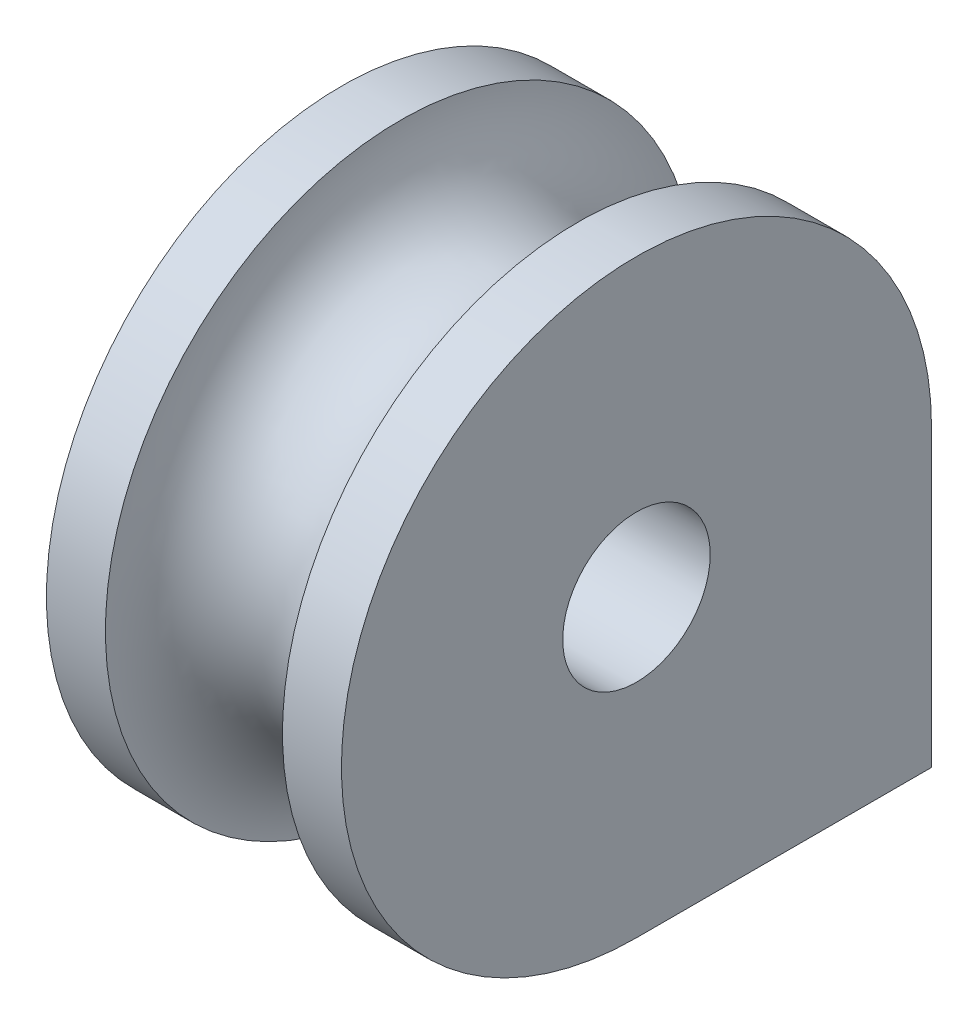
from build123d import *

# Parameters (mm, degrees)
REVOLVE1_ANGLE      = 270
BOSS_EXTRUDE1_DEPTH = 50
SKETCH3_R           = 12.5
CUT_EXTRUDE2_DEPTH  = 51


with BuildPart() as part:
    # Sketch1 → Revolve1 (revolve)
    with BuildSketch(Plane(origin=(0, 0, 0), x_dir=(1, 0, 0), z_dir=(0, 1, 0))):
        with BuildLine():
            Line((15, 50), (25, 50))
            Line((25, 50), (25, 0))
            Line((25, 0), (-25, 0))
            Line((-25, 0), (-25, 50))
            Line((-25, 50), (-15, 50))
            ThreePointArc((-15, 50), (0, 35), (15, 50))
        make_face()
    revolve(axis=Axis((-25, 0, 0), (1, 0, 0)), revolution_arc=REVOLVE1_ANGLE)

    # Sketch1_2 → Boss-Extrude1 (add)
    with BuildSketch(Plane(origin=(0, 0, 0), x_dir=(1, 0, 0), z_dir=(0, 1, 0))):
        with BuildLine():
            Line((15, 50), (25, 50))
            Line((25, 50), (25, 0))
            Line((25, 0), (-25, 0))
            Line((-25, 0), (-25, 50))
            Line((-25, 50), (-15, 50))
            ThreePointArc((-15, 50), (0, 35), (15, 50))
        make_face()
    extrude(amount=-BOSS_EXTRUDE1_DEPTH)

    # Sketch3 → Cut-Extrude2 (cut, through all)
    with BuildSketch(Plane(origin=(25, 0, 0), x_dir=(0, 0, -1), z_dir=(1, 0, 0))):
        Circle(SKETCH3_R)
    extrude(amount=-CUT_EXTRUDE2_DEPTH, mode=Mode.SUBTRACT)


solid = part.part
